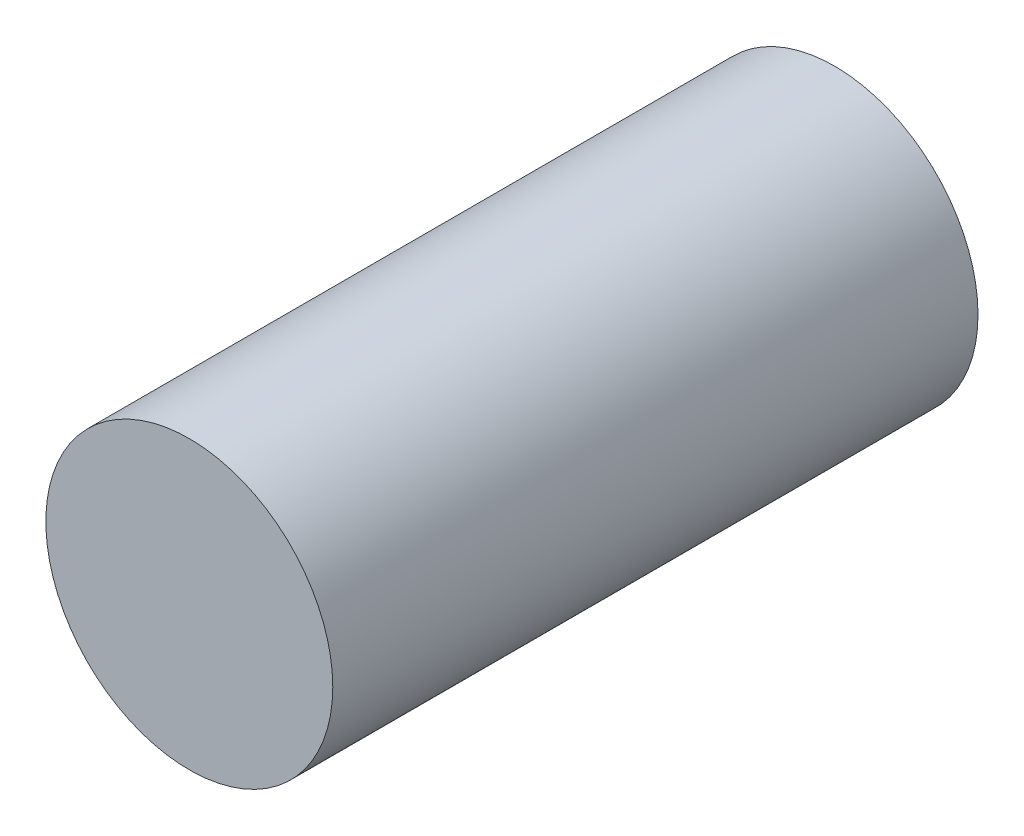
from build123d import *

# Parameters (mm, degrees)
SCHIZZO1_R                   = 58.7
ESTRUSIONE_ESTRUSIONE1_DEPTH = 5
SCHIZZO2_R                   = 58.7
SCHIZZO2_R_2                 = 48.7
ESTRUSIONE_ESTRUSIONE2_DEPTH = 254
SCHIZZO3_R                   = 58.7
ESTRUSIONE_ESTRUSIONE3_DEPTH = 5


with BuildPart() as part:
    # Schizzo1 → Estrusione-Estrusione1 (new body)
    with BuildSketch(Plane.XY):
        Circle(SCHIZZO1_R)
    extrude(amount=ESTRUSIONE_ESTRUSIONE1_DEPTH)

    # Schizzo2 → Estrusione-Estrusione2 (add)
    with BuildSketch(Plane.XY.offset(5)):
        Circle(SCHIZZO2_R)
        Circle(SCHIZZO2_R_2, mode=Mode.SUBTRACT)
    extrude(amount=ESTRUSIONE_ESTRUSIONE2_DEPTH)

    # Schizzo3 → Estrusione-Estrusione3 (add)
    with BuildSketch(Plane.XY.offset(259)):
        Circle(SCHIZZO3_R)
    extrude(amount=ESTRUSIONE_ESTRUSIONE3_DEPTH)


solid = part.part
